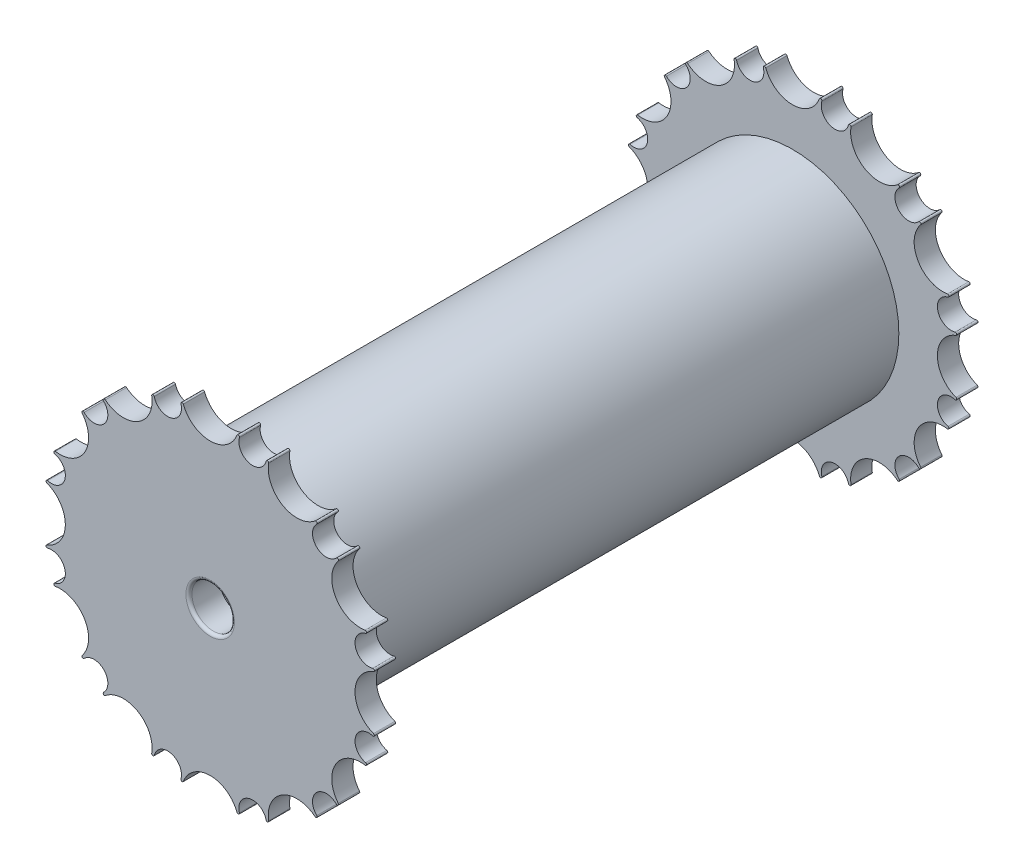
from build123d import *

# Parameters (mm, degrees)
BOSS_EXTRUDE1_DEPTH = 2.5
SKETCH5_R           = 20
SKETCH5_R_2         = 10
BOSS_EXTRUDE2_DEPTH = 1
BOSS_EXTRUDE3_DEPTH = 1.5
BOSS_EXTRUDE4_START = -66
SKETCH9_R           = 25
BOSS_EXTRUDE4_DEPTH = 132
SCALE1_SCALE        = 0.7
SKETCH11_R          = 3.5
CUT_EXTRUDE1_DEPTH  = 5
SKETCH12_R          = 3.5
CUT_EXTRUDE2_DEPTH  = 5
FILLET1_R           = 0.5


with BuildPart() as part:
    # Sketch4 → Boss-Extrude1 (new body, symmetric)
    with BuildSketch(Plane.XY):
        with BuildLine():
            ThreePointArc((-24.679485793, 30.123197595), (-25.095377084, 30.089266142), (-25.07747192, 29.672377291))
            ThreePointArc((-25.07747192, 29.672377291), (-24.070735897, 27.35898907), (-25.022411037, 25.022411037))
            ThreePointArc((-25.022411037, 25.022411037), (-27.35898907, 24.070735897), (-29.672377291, 25.07747192))
            ThreePointArc((-29.672377291, 25.07747192), (-30.089266142, 25.095377084), (-30.123197595, 24.679485793))
            ThreePointArc((-30.123197595, 24.679485793), (-29.505925513, 17.035254038), (-36.434660446, 13.747711464))
            ThreePointArc((-36.434660446, 13.747711464), (-36.777867143, 13.510380319), (-36.553916391, 13.158296564))
            ThreePointArc((-36.553916391, 13.158296564), (-34.52536331, 11.658211608), (-34.18124914, 9.158838103))
            ThreePointArc((-34.18124914, 9.158838103), (-35.728947505, 7.16637424), (-38.235768484, 6.8815391))
            ThreePointArc((-38.235768484, 6.8815391), (-38.605757403, 6.688601001), (-38.427197257, 6.311462851))
            ThreePointArc((-38.427197257, 6.311462851), (-34.070508076, 0), (-38.427197257, -6.311462851))
            ThreePointArc((-38.427197257, -6.311462851), (-38.605757403, -6.688601001), (-38.235768484, -6.8815391))
            ThreePointArc((-38.235768484, -6.8815391), (-35.728947505, -7.16637424), (-34.18124914, -9.158838103))
            ThreePointArc((-34.18124914, -9.158838103), (-34.52536331, -11.658211608), (-36.553916391, -13.158296564))
            ThreePointArc((-36.553916391, -13.158296564), (-36.777867143, -13.510380319), (-36.434660446, -13.747711464))
            ThreePointArc((-36.434660446, -13.747711464), (-29.505925513, -17.035254038), (-30.123197595, -24.679485793))
            ThreePointArc((-30.123197595, -24.679485793), (-30.089266142, -25.095377084), (-29.672377291, -25.07747192))
            ThreePointArc((-29.672377291, -25.07747192), (-27.35898907, -24.070735897), (-25.022411037, -25.022411037))
            ThreePointArc((-25.022411037, -25.022411037), (-24.070735897, -27.35898907), (-25.07747192, -29.672377291))
            ThreePointArc((-25.07747192, -29.672377291), (-25.095377084, -30.089266142), (-24.679485793, -30.123197595))
            ThreePointArc((-24.679485793, -30.123197595), (-17.035254038, -29.505925513), (-13.747711464, -36.434660446))
            ThreePointArc((-13.747711464, -36.434660446), (-13.510380319, -36.777867143), (-13.158296564, -36.553916391))
            ThreePointArc((-13.158296564, -36.553916391), (-11.658211608, -34.52536331), (-9.158838103, -34.18124914))
            ThreePointArc((-9.158838103, -34.18124914), (-7.16637424, -35.728947505), (-6.8815391, -38.235768484))
            ThreePointArc((-6.8815391, -38.235768484), (-6.688601001, -38.605757403), (-6.311462851, -38.427197257))
            ThreePointArc((-6.311462851, -38.427197257), (0, -34.070508076), (6.311462851, -38.427197257))
            ThreePointArc((6.311462851, -38.427197257), (6.688601001, -38.605757403), (6.8815391, -38.235768484))
            ThreePointArc((6.8815391, -38.235768484), (7.16637424, -35.728947505), (9.158838103, -34.18124914))
            ThreePointArc((9.158838103, -34.18124914), (11.658211608, -34.52536331), (13.158296564, -36.553916391))
            ThreePointArc((13.158296564, -36.553916391), (13.510380319, -36.777867143), (13.747711464, -36.434660446))
            ThreePointArc((13.747711464, -36.434660446), (17.035254038, -29.505925513), (24.679485793, -30.123197595))
            ThreePointArc((24.679485793, -30.123197595), (25.095377084, -30.089266142), (25.07747192, -29.672377291))
            ThreePointArc((25.07747192, -29.672377291), (24.070735897, -27.35898907), (25.022411037, -25.022411037))
            ThreePointArc((25.022411037, -25.022411037), (27.35898907, -24.070735897), (29.672377291, -25.07747192))
            ThreePointArc((29.672377291, -25.07747192), (30.089266142, -25.095377084), (30.123197595, -24.679485793))
            ThreePointArc((30.123197595, -24.679485793), (29.505925513, -17.035254038), (36.434660446, -13.747711464))
            ThreePointArc((36.434660446, -13.747711464), (36.777867143, -13.510380319), (36.553916391, -13.158296564))
            ThreePointArc((36.553916391, -13.158296564), (34.52536331, -11.658211608), (34.18124914, -9.158838103))
            ThreePointArc((34.18124914, -9.158838103), (35.728947505, -7.16637424), (38.235768484, -6.8815391))
            ThreePointArc((38.235768484, -6.8815391), (38.605757403, -6.688601001), (38.427197257, -6.311462851))
            ThreePointArc((38.427197257, -6.311462851), (34.070508076, 0), (38.427197257, 6.311462851))
            ThreePointArc((38.427197257, 6.311462851), (38.605757403, 6.688601001), (38.235768484, 6.8815391))
            ThreePointArc((38.235768484, 6.8815391), (35.728947505, 7.16637424), (34.18124914, 9.158838103))
            ThreePointArc((34.18124914, 9.158838103), (34.52536331, 11.658211608), (36.553916391, 13.158296564))
            ThreePointArc((36.553916391, 13.158296564), (36.777867143, 13.510380319), (36.434660446, 13.747711464))
            ThreePointArc((36.434660446, 13.747711464), (29.505925513, 17.035254038), (30.123197595, 24.679485793))
            ThreePointArc((30.123197595, 24.679485793), (30.089266142, 25.095377084), (29.672377291, 25.07747192))
            ThreePointArc((29.672377291, 25.07747192), (27.35898907, 24.070735897), (25.022411037, 25.022411037))
            ThreePointArc((25.022411037, 25.022411037), (24.070735897, 27.35898907), (25.07747192, 29.672377291))
            ThreePointArc((25.07747192, 29.672377291), (25.095377084, 30.089266142), (24.679485793, 30.123197595))
            ThreePointArc((24.679485793, 30.123197595), (17.035254038, 29.505925513), (13.747711464, 36.434660446))
            ThreePointArc((13.747711464, 36.434660446), (13.510380319, 36.777867143), (13.158296564, 36.553916391))
            ThreePointArc((13.158296564, 36.553916391), (11.658211608, 34.52536331), (9.158838103, 34.18124914))
            ThreePointArc((9.158838103, 34.18124914), (7.16637424, 35.728947505), (6.8815391, 38.235768484))
            ThreePointArc((6.8815391, 38.235768484), (6.688601001, 38.605757403), (6.311462851, 38.427197257))
            ThreePointArc((6.311462851, 38.427197257), (0, 34.070508076), (-6.311462851, 38.427197257))
            ThreePointArc((-6.311462851, 38.427197257), (-6.688601001, 38.605757403), (-6.8815391, 38.235768484))
            ThreePointArc((-6.8815391, 38.235768484), (-7.16637424, 35.728947505), (-9.158838103, 34.18124914))
            ThreePointArc((-9.158838103, 34.18124914), (-11.658211608, 34.52536331), (-13.158296564, 36.553916391))
            ThreePointArc((-13.158296564, 36.553916391), (-13.510380319, 36.777867143), (-13.747711464, 36.434660446))
            ThreePointArc((-13.747711464, 36.434660446), (-17.035254038, 29.505925513), (-24.679485793, 30.123197595))
        make_face()
    extrude(amount=BOSS_EXTRUDE1_DEPTH, both=True)



with BuildPart() as body_2:
    # Sketch5 → Boss-Extrude2 (new body, symmetric)
    with BuildSketch(Plane.XY):
        Circle(SKETCH5_R)
        Circle(SKETCH5_R_2, mode=Mode.SUBTRACT)
    extrude(amount=BOSS_EXTRUDE2_DEPTH, both=True)


with BuildPart() as part_1:
    add(part.part)

    add(body_2.part)  # Boss-Extrude3 merges body 2
    # Sketch6 → Boss-Extrude3 (add)
    with BuildSketch(Plane.XY.offset(1)):
        with BuildLine():
            Line((0.75, 29.990623535), (0.75, 19.990623535))
            ThreePointArc((0.75, 19.990623535), (0, 19.240623535), (-0.75, 19.990623535))
            Line((-0.75, 19.990623535), (-0.75, 29.990623535))
            ThreePointArc((-0.75, 29.990623535), (0, 30.740623535), (0.75, 29.990623535))
        make_face()
        with BuildLine():
            Line((25.597641856, 15.64483082), (16.937387819, 10.64483082))
            ThreePointArc((16.937387819, 10.64483082), (16.662868766, 9.620311767), (17.687387819, 9.345792715))
            Line((17.687387819, 9.345792715), (26.347641856, 14.345792715))
            ThreePointArc((26.347641856, 14.345792715), (26.622160909, 15.370311767), (25.597641856, 15.64483082))
        make_face()
        with BuildLine():
            Line((26.347641856, -14.345792715), (17.687387819, -9.345792715))
            ThreePointArc((17.687387819, -9.345792715), (16.662868766, -9.620311767), (16.937387819, -10.64483082))
            Line((16.937387819, -10.64483082), (25.597641856, -15.64483082))
            ThreePointArc((25.597641856, -15.64483082), (26.622160909, -15.370311767), (26.347641856, -14.345792715))
        make_face()
        with BuildLine():
            Line((0.75, -29.990623535), (0.75, -19.990623535))
            ThreePointArc((0.75, -19.990623535), (0, -19.240623535), (-0.75, -19.990623535))
            Line((-0.75, -19.990623535), (-0.75, -29.990623535))
            ThreePointArc((-0.75, -29.990623535), (0, -30.740623535), (0.75, -29.990623535))
        make_face()
        with BuildLine():
            Line((-25.597641856, -15.64483082), (-16.937387819, -10.64483082))
            ThreePointArc((-16.937387819, -10.64483082), (-16.662868766, -9.620311767), (-17.687387819, -9.345792715))
            Line((-17.687387819, -9.345792715), (-26.347641856, -14.345792715))
            ThreePointArc((-26.347641856, -14.345792715), (-26.622160909, -15.370311767), (-25.597641856, -15.64483082))
        make_face()
        with BuildLine():
            Line((-26.347641856, 14.345792715), (-17.687387819, 9.345792715))
            ThreePointArc((-17.687387819, 9.345792715), (-16.662868766, 9.620311767), (-16.937387819, 10.64483082))
            Line((-16.937387819, 10.64483082), (-25.597641856, 15.64483082))
            ThreePointArc((-25.597641856, 15.64483082), (-26.622160909, 15.370311767), (-26.347641856, 14.345792715))
        make_face()
    extrude(amount=-BOSS_EXTRUDE3_DEPTH)


with BuildPart() as body_2_2:
    # Mirror2: mirrored copy
    add(part_1.part.mirror(Plane.XY.offset(68.5)))


with BuildPart() as part_2:
    add(part_1.part)

    add(body_2_2.part)  # Boss-Extrude4 merges body 2 2
    # Sketch9 → Boss-Extrude4 (add)
    with BuildSketch(Plane.XY.offset(68.5).offset(BOSS_EXTRUDE4_START)):
        Circle(SKETCH9_R)
    extrude(amount=BOSS_EXTRUDE4_DEPTH)


with BuildPart() as part_3:
    # Scale1: scaled about (0, 0, 0)
    add(part_2.part.scale(SCALE1_SCALE))

    # Sketch11 → Cut-Extrude1 (cut)
    with BuildSketch(Plane.XY.offset(97.65)):
        Circle(SKETCH11_R)
    extrude(amount=-CUT_EXTRUDE1_DEPTH, mode=Mode.SUBTRACT)

    # Sketch12 → Cut-Extrude2 (cut)
    with BuildSketch(Plane(origin=(0, 0, -1.75), x_dir=(-1, 0, 0), z_dir=(0, 0, -1))):
        with Locations(Location((0, 0, 0), (0, 0, 180))):  # turned: the seam where the file's is
            Circle(SKETCH12_R)
    extrude(amount=-CUT_EXTRUDE2_DEPTH, mode=Mode.SUBTRACT)

    # Fillet1
    fillet1_edges = [part_3.edges().sort_by_distance(p)[0] for p in [
        (-3.5, 0, 97.65),
        (-3.5, 0, -1.75),
    ]]
    fillet(fillet1_edges, radius=FILLET1_R)


solid = part_3.part
